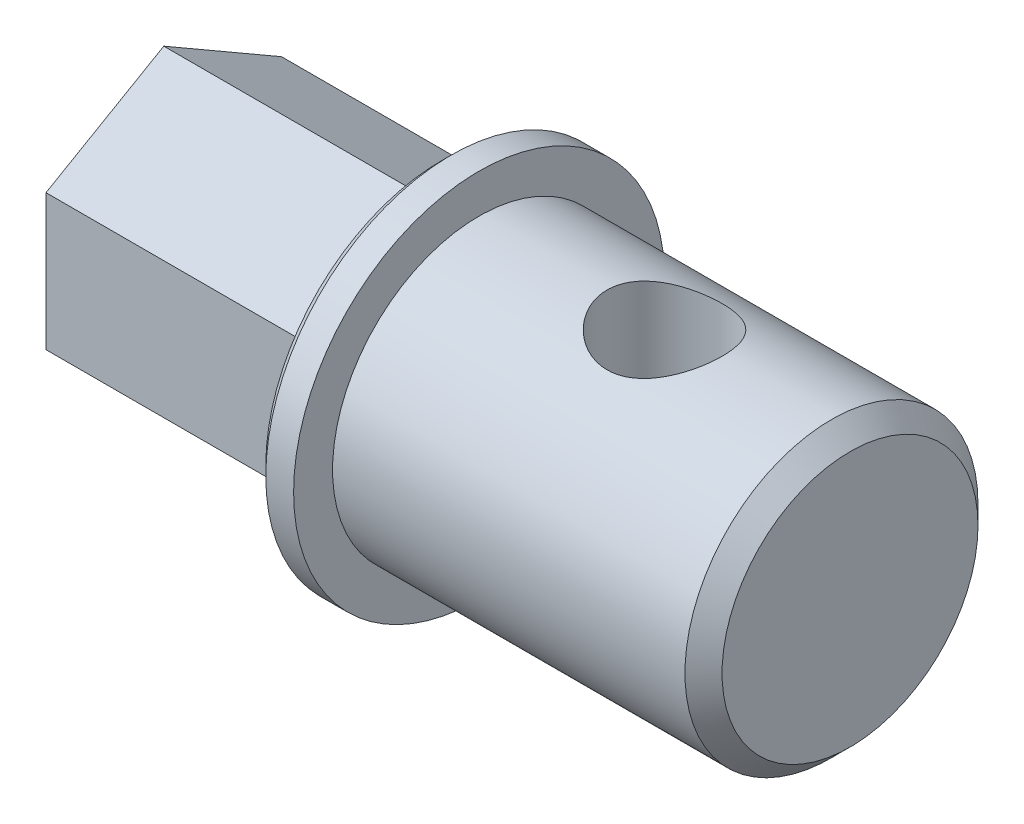
from build123d import *

# Parameters (mm, degrees)
SKETCH_1_R               = 7.9
EXTRUDE_1_DEPTH          = 20
SKETCH_3_R               = 10
EXTRUDE_2_DEPTH          = 2
EXTRUDE_3_DEPTH          = 15
CHAMFER_1_SIZE           = 0.5
M5X0_8_1_D               = 4.2
M5X0_8_1_DEPTH           = 12.4
M5X0_8_1_TIP             = 1.2618073
SKETCH_5_R               = 3.1
CUT_EXTRUDE_1_DEPTH      = 11
CUT_EXTRUDE_1_DEPTH_BACK = 11
CHAMFER_2_SIZE           = 1


with BuildPart() as part:
    # 草图1 → 凸台-拉伸1 (new body)
    with BuildSketch(Plane(origin=(0, 0, 0), x_dir=(0, 0, -1), z_dir=(1, 0, 0))):
        Circle(SKETCH_1_R)
    extrude(amount=EXTRUDE_1_DEPTH)

    # 草图3 → 凸台-拉伸2 (add)
    with BuildSketch(Plane.ZY):
        Circle(SKETCH_3_R)
    extrude(amount=EXTRUDE_2_DEPTH)

    # 草图4 → 凸台-拉伸3 (add)
    with BuildSketch(Plane.ZY.offset(2)):
        Polygon((6.35, 3.666174209), (0, 7.332348419), (-6.35, 3.666174209), (-6.35, -3.666174209), (0, -7.332348419), (6.35, -3.666174209), align=None)
    extrude(amount=EXTRUDE_3_DEPTH)

    # 倒角1
    chamfer_1_edges = [part.edges().sort_by_distance(p)[0] for p in [
        (-2, 0, -10),
    ]]
    chamfer(chamfer_1_edges, length=CHAMFER_1_SIZE)

    # M5x0.8 螺纹孔1
    with Locations(Plane.ZY.offset(17)):
        with Locations((0, 0)):
            Hole(M5X0_8_1_D / 2, depth=M5X0_8_1_DEPTH)
            with Locations((0, 0, -(M5X0_8_1_DEPTH + M5X0_8_1_TIP / 2))):  # 118° drill point
                Cone(0, M5X0_8_1_D / 2, M5X0_8_1_TIP, mode=Mode.SUBTRACT)

    # 草图5 → 切除-拉伸1 (cut, two sides)
    with BuildSketch(Plane(origin=(0, 0, 0), x_dir=(1, 0, 0), z_dir=(0, 1, 0))) as cut_extrude_1_sk:
        with Locations((10, 0)):
            Circle(SKETCH_5_R)
    extrude(amount=CUT_EXTRUDE_1_DEPTH, mode=Mode.SUBTRACT)
    extrude(cut_extrude_1_sk.sketch, amount=-CUT_EXTRUDE_1_DEPTH_BACK, mode=Mode.SUBTRACT)

    # 倒角2
    chamfer_2_edges = [part.edges().sort_by_distance(p)[0] for p in [
        (20, 0, 7.9),
    ]]
    chamfer(chamfer_2_edges, length=CHAMFER_2_SIZE)


solid = part.part
